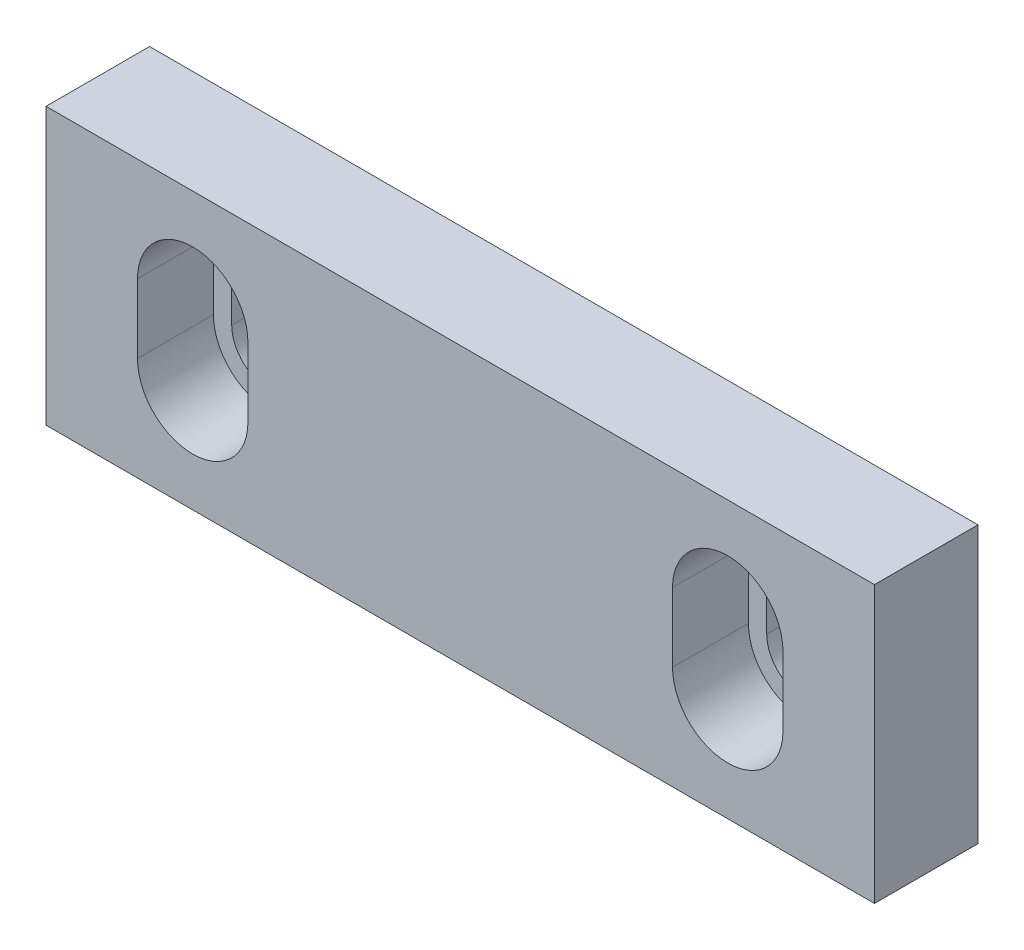
from build123d import *

# Parameters (mm, degrees)
SKETCH1_W           = 152.4
SKETCH1_H           = 50.8
BOSS_EXTRUDE1_DEPTH = 19.05
BOSS_EXTRUDE2_DEPTH = 5.08


with BuildPart() as part:
    # Sketch1 → Boss-Extrude1 (new body)
    with BuildSketch(Plane.XY):
        Rectangle(SKETCH1_W, SKETCH1_H)
        with BuildLine():
            ThreePointArc((-39.0525, -6.35), (-49.2125, -16.51), (-59.3725, -6.35))
            Line((-59.3725, -6.35), (-59.3725, 6.35))
            ThreePointArc((-59.3725, 6.35), (-49.2125, 16.51), (-39.0525, 6.35))
            Line((-39.0525, 6.35), (-39.0525, -6.35))
        make_face(mode=Mode.SUBTRACT)
        with BuildLine():
            ThreePointArc((59.3725, -6.35), (49.2125, -16.51), (39.0525, -6.35))
            Line((39.0525, -6.35), (39.0525, 6.35))
            ThreePointArc((39.0525, 6.35), (49.2125, 16.51), (59.3725, 6.35))
            Line((59.3725, 6.35), (59.3725, -6.35))
        make_face(mode=Mode.SUBTRACT)
    extrude(amount=BOSS_EXTRUDE1_DEPTH)

    # Sketch1_3 → Boss-Extrude2 (add)
    # profile 1 of 2: a face of its own
    with BuildSketch(Plane.XY):
        with BuildLine():
            Line((-59.3725, 6.35), (-59.3725, -6.35))
            ThreePointArc((-59.3725, -6.35), (-49.2125, -16.51), (-39.0525, -6.35))
            Line((-39.0525, -6.35), (-39.0525, 6.35))
            ThreePointArc((-39.0525, 6.35), (-49.2125, 16.51), (-59.3725, 6.35))
        make_face()
        with BuildLine():
            ThreePointArc((-42.418, -6.35), (-49.2125, -13.1445), (-56.007, -6.35))
            Line((-56.007, -6.35), (-56.007, 6.35))
            ThreePointArc((-56.007, 6.35), (-49.2125, 13.1445), (-42.418, 6.35))
            Line((-42.418, 6.35), (-42.418, -6.35))
        make_face(mode=Mode.SUBTRACT)
    # profile 2 of 2: a face of its own
    with BuildSketch(Plane.XY):
        with BuildLine():
            Line((39.0525, 6.35), (39.0525, -6.35))
            ThreePointArc((39.0525, -6.35), (49.2125, -16.51), (59.3725, -6.35))
            Line((59.3725, -6.35), (59.3725, 6.35))
            ThreePointArc((59.3725, 6.35), (49.2125, 16.51), (39.0525, 6.35))
        make_face()
        with BuildLine():
            ThreePointArc((56.007, -6.35), (49.2125, -13.1445), (42.418, -6.35))
            Line((42.418, -6.35), (42.418, 6.35))
            ThreePointArc((42.418, 6.35), (49.2125, 13.1445), (56.007, 6.35))
            Line((56.007, 6.35), (56.007, -6.35))
        make_face(mode=Mode.SUBTRACT)
    extrude(amount=BOSS_EXTRUDE2_DEPTH)


solid = part.part
